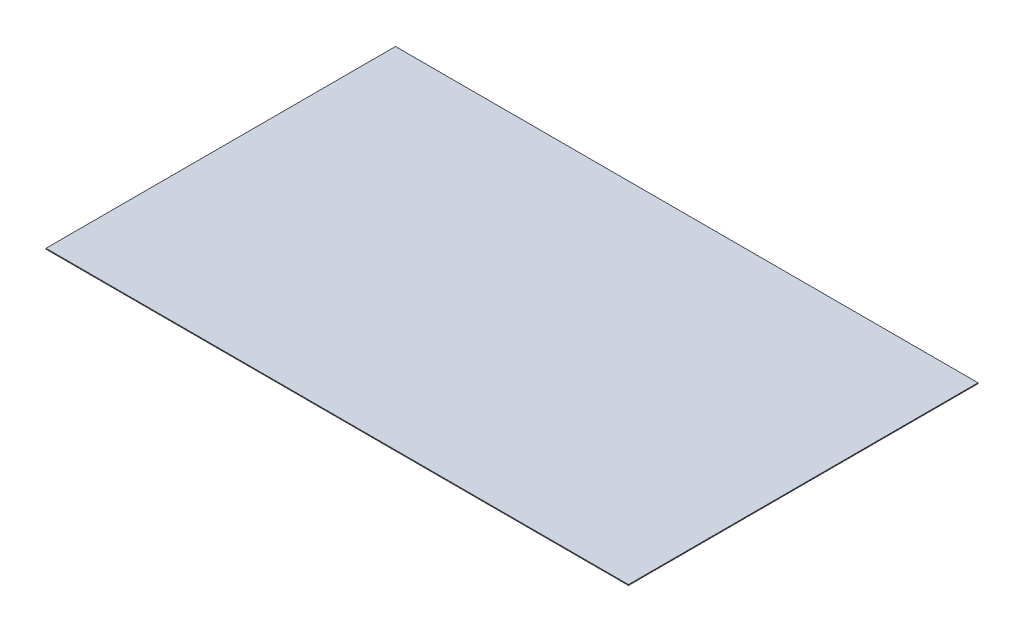
from build123d import *

# Parameters (mm, degrees)
SKETCH1_W           = 25
SKETCH1_H           = 15
BOSS_EXTRUDE1_DEPTH = 0.035


with BuildPart() as part:
    # Sketch1 → Boss-Extrude1 (new body)
    with BuildSketch(Plane(origin=(0, 0, 0), x_dir=(1, 0, 0), z_dir=(0, 1, 0))):
        with Locations((12.5, 7.5)):
            Rectangle(SKETCH1_W, SKETCH1_H)
    extrude(amount=BOSS_EXTRUDE1_DEPTH)


solid = part.part
